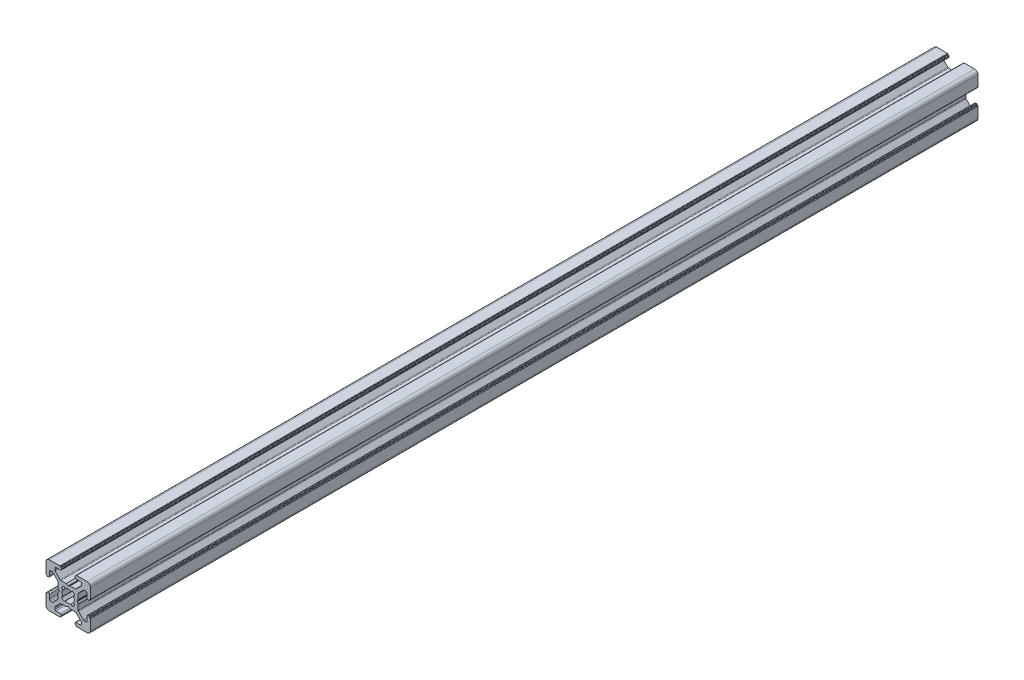
from build123d import *

# Parameters (mm, degrees)
DODANIE_WYCI_GNI_CIE1_DEPTH = 400


with BuildPart() as part:
    # Szkic1 → Dodanie-wyciągnięcie1 (new body)
    with BuildSketch(Plane.XY):
        with BuildLine():
            Line((6.249999773, 6.250000395), (1.5, 6.250000395))
            ThreePointArc((1.5, 6.250000395), (0.439339828, 5.810660567), (0, 4.750000395))
            Line((0, 4.750000395), (0, 0))
            ThreePointArc((0, 0), (0.058578644, -0.141421356), (0.2, -0.2))
            Line((0.2, -0.2), (0.300000268, -0.2))
            ThreePointArc((0.300000268, -0.2), (0.441421624, -0.258578644), (0.500000268, -0.4))
            Line((0.500000268, -0.4), (0.500000268, -0.549999605))
            ThreePointArc((0.500000268, -0.549999605), (0.558578912, -0.691420961), (0.700000268, -0.749999605))
            Line((0.700000268, -0.749999605), (1.000000268, -0.749999605))
            ThreePointArc((1.000000268, -0.749999605), (1.353553659, -0.603552995), (1.500000268, -0.249999605))
            Line((1.500000268, -0.249999605), (1.500000268, 1.75))
            ThreePointArc((1.500000268, 1.75), (1.646446877, 2.103553391), (2.000000268, 2.25))
            Line((2.000000268, 2.25), (2.732233315, 2.25))
            ThreePointArc((2.732233315, 2.25), (2.923575031, 2.211939766), (3.085786706, 2.103553391))
            Line((3.085786706, 2.103553391), (5.353553602, -0.164213506))
            ThreePointArc((5.353553602, -0.164213506), (5.461939977, -0.32642518), (5.500000211, -0.517766896))
            Line((5.500000211, -0.517766896), (5.500000211, -2.796410303))
            ThreePointArc((5.500000211, -2.796410303), (5.506815047, -2.848174114), (5.526795133, -2.896410307))
            Line((5.526795133, -2.896410307), (5.961880159, -3.649999636))
            ThreePointArc((5.961880159, -3.649999636), (5.988675071, -3.749999605), (5.961880159, -3.849999574))
            Line((5.961880159, -3.849999574), (5.526795133, -4.603588902))
            ThreePointArc((5.526795133, -4.603588902), (5.506815046, -4.651825095), (5.500000211, -4.703588906))
            Line((5.500000211, -4.703588906), (5.500000211, -6.982232313))
            ThreePointArc((5.500000211, -6.982232313), (5.461939977, -7.173574029), (5.353553602, -7.335785704))
            Line((5.353553602, -7.335785704), (3.085786706, -9.6035526))
            ThreePointArc((3.085786706, -9.6035526), (2.923575031, -9.711938976), (2.732233315, -9.749999209))
            Line((2.732233315, -9.749999209), (2.000000268, -9.749999209))
            ThreePointArc((2.000000268, -9.749999209), (1.646446877, -9.6035526), (1.500000268, -9.249999209))
            Line((1.500000268, -9.249999209), (1.500000268, -7.249999605))
            ThreePointArc((1.500000268, -7.249999605), (1.353553659, -6.896446214), (1.000000268, -6.749999605))
            Line((1.000000268, -6.749999605), (0.700000268, -6.749999605))
            ThreePointArc((0.700000268, -6.749999605), (0.558578912, -6.808578248), (0.500000268, -6.949999605))
            Line((0.500000268, -6.949999605), (0.500000268, -7.099999209))
            ThreePointArc((0.500000268, -7.099999209), (0.441421624, -7.241420566), (0.300000268, -7.299999209))
            Line((0.300000268, -7.299999209), (0.2, -7.299999209))
            ThreePointArc((0.2, -7.299999209), (0.058578644, -7.358577853), (0, -7.499999209))
            Line((0, -7.499999209), (0, -12.249999605))
            ThreePointArc((0, -12.249999605), (0.439339828, -13.310659776), (1.5, -13.749999605))
            Line((1.5, -13.749999605), (6.249999772, -13.749999605))
            ThreePointArc((6.249999772, -13.749999605), (6.391421129, -13.691420961), (6.449999772, -13.549999605))
            Line((6.449999772, -13.549999605), (6.449999772, -13.449999605))
            ThreePointArc((6.449999772, -13.449999605), (6.508578416, -13.308578248), (6.649999772, -13.249999605))
            Line((6.649999772, -13.249999605), (6.8, -13.249999605))
            ThreePointArc((6.8, -13.249999605), (6.941421356, -13.191420961), (7, -13.049999605))
            Line((7, -13.049999605), (7, -12.749999278))
            ThreePointArc((7, -12.749999278), (6.853553391, -12.396445888), (6.5, -12.249999278))
            Line((6.5, -12.249999278), (4.499999314, -12.249999278))
            ThreePointArc((4.499999314, -12.249999278), (4.146445923, -12.103552669), (3.999999314, -11.749999278))
            Line((3.999999314, -11.749999278), (3.999999314, -11.017766231))
            ThreePointArc((3.999999314, -11.017766231), (4.038059552, -10.826424504), (4.146445941, -10.664212823))
            Line((4.146445941, -10.664212823), (6.414212788, -8.396446197))
            ThreePointArc((6.414212788, -8.396446197), (6.576424456, -8.288059834), (6.767766161, -8.249999605))
            Line((6.767766161, -8.249999605), (9.046409688, -8.249999605))
            ThreePointArc((9.046409688, -8.249999605), (9.098173495, -8.243184771), (9.146409684, -8.223204688))
            Line((9.146409684, -8.223204688), (9.899999955, -7.788119166))
            ThreePointArc((9.899999955, -7.788119166), (10, -7.761324236), (10.100000045, -7.788119166))
            Line((10.100000045, -7.788119166), (10.853590316, -8.223204688))
            ThreePointArc((10.853590316, -8.223204688), (10.901826505, -8.243184771), (10.953590312, -8.249999605))
            Line((10.953590312, -8.249999605), (13.232233839, -8.249999605))
            ThreePointArc((13.232233839, -8.249999605), (13.423575544, -8.288059834), (13.585787212, -8.396446197))
            Line((13.585787212, -8.396446197), (15.853554059, -10.664212823))
            ThreePointArc((15.853554059, -10.664212823), (15.961940448, -10.826424504), (16.000000686, -11.017766231))
            Line((16.000000686, -11.017766231), (16.000000686, -11.749999278))
            ThreePointArc((16.000000686, -11.749999278), (15.853554077, -12.103552669), (15.500000686, -12.249999278))
            Line((15.500000686, -12.249999278), (13.5, -12.249999278))
            ThreePointArc((13.5, -12.249999278), (13.146446609, -12.396445888), (13, -12.749999278))
            Line((13, -12.749999278), (13, -13.049999605))
            ThreePointArc((13, -13.049999605), (13.058578644, -13.191420961), (13.2, -13.249999605))
            Line((13.2, -13.249999605), (13.350000227, -13.249999605))
            ThreePointArc((13.350000227, -13.249999605), (13.491421584, -13.308578248), (13.550000227, -13.449999605))
            Line((13.550000227, -13.449999605), (13.550000227, -13.549999605))
            ThreePointArc((13.550000227, -13.549999605), (13.608578871, -13.691420961), (13.750000227, -13.749999605))
            Line((13.750000227, -13.749999605), (18.5, -13.749999605))
            ThreePointArc((18.5, -13.749999605), (19.560660172, -13.310659776), (20, -12.249999605))
            Line((20, -12.249999605), (20, -7.499999209))
            ThreePointArc((20, -7.499999209), (19.941421356, -7.358577853), (19.8, -7.299999209))
            Line((19.8, -7.299999209), (19.699999732, -7.299999209))
            ThreePointArc((19.699999732, -7.299999209), (19.558578376, -7.241420566), (19.499999732, -7.099999209))
            Line((19.499999732, -7.099999209), (19.499999732, -6.949999605))
            ThreePointArc((19.499999732, -6.949999605), (19.441421088, -6.808578248), (19.299999732, -6.749999605))
            Line((19.299999732, -6.749999605), (18.999999732, -6.749999605))
            ThreePointArc((18.999999732, -6.749999605), (18.646446341, -6.896446214), (18.499999732, -7.249999605))
            Line((18.499999732, -7.249999605), (18.499999732, -9.249999209))
            ThreePointArc((18.499999732, -9.249999209), (18.353553123, -9.6035526), (17.999999732, -9.749999209))
            Line((17.999999732, -9.749999209), (17.267766685, -9.749999209))
            ThreePointArc((17.267766685, -9.749999209), (17.076424969, -9.711938976), (16.914213294, -9.6035526))
            Line((16.914213294, -9.6035526), (14.646446398, -7.335785704))
            ThreePointArc((14.646446398, -7.335785704), (14.538060023, -7.173574029), (14.499999789, -6.982232313))
            Line((14.499999789, -6.982232313), (14.499999789, -4.703588906))
            ThreePointArc((14.499999789, -4.703588906), (14.493184953, -4.651825095), (14.473204867, -4.603588902))
            Line((14.473204867, -4.603588902), (14.038119841, -3.849999574))
            ThreePointArc((14.038119841, -3.849999574), (14.011324929, -3.749999605), (14.038119841, -3.649999636))
            Line((14.038119841, -3.649999636), (14.473204867, -2.896410307))
            ThreePointArc((14.473204867, -2.896410307), (14.493184953, -2.848174114), (14.499999789, -2.796410303))
            Line((14.499999789, -2.796410303), (14.499999789, -0.517766896))
            ThreePointArc((14.499999789, -0.517766896), (14.538060023, -0.32642518), (14.646446398, -0.164213506))
            Line((14.646446398, -0.164213506), (16.914213294, 2.103553391))
            ThreePointArc((16.914213294, 2.103553391), (17.076424969, 2.211939766), (17.267766685, 2.25))
            Line((17.267766685, 2.25), (17.999999732, 2.25))
            ThreePointArc((17.999999732, 2.25), (18.353553123, 2.103553391), (18.499999732, 1.75))
            Line((18.499999732, 1.75), (18.499999732, -0.249999605))
            ThreePointArc((18.499999732, -0.249999605), (18.646446341, -0.603552995), (18.999999732, -0.749999605))
            Line((18.999999732, -0.749999605), (19.299999732, -0.749999605))
            ThreePointArc((19.299999732, -0.749999605), (19.441421088, -0.691420961), (19.499999732, -0.549999605))
            Line((19.499999732, -0.549999605), (19.499999732, -0.4))
            ThreePointArc((19.499999732, -0.4), (19.558578376, -0.258578644), (19.699999732, -0.2))
            Line((19.699999732, -0.2), (19.8, -0.2))
            ThreePointArc((19.8, -0.2), (19.941421356, -0.141421356), (20, 0))
            Line((20, 0), (20, 4.750000395))
            ThreePointArc((20, 4.750000395), (19.560660172, 5.810660567), (18.5, 6.250000395))
            Line((18.5, 6.250000395), (13.750000228, 6.250000395))
            ThreePointArc((13.750000228, 6.250000395), (13.608578871, 6.191421752), (13.550000228, 6.050000395))
            Line((13.550000228, 6.050000395), (13.550000228, 5.950000395))
            ThreePointArc((13.550000228, 5.950000395), (13.491421584, 5.808579039), (13.350000228, 5.750000395))
            Line((13.350000228, 5.750000395), (13.2, 5.750000395))
            ThreePointArc((13.2, 5.750000395), (13.058578644, 5.691421752), (13, 5.550000395))
            Line((13, 5.550000395), (13, 5.250000069))
            ThreePointArc((13, 5.250000069), (13.146446609, 4.896446678), (13.5, 4.750000069))
            Line((13.5, 4.750000069), (15.500000686, 4.750000069))
            ThreePointArc((15.500000686, 4.750000069), (15.853554077, 4.603553459), (16.000000686, 4.250000069))
            Line((16.000000686, 4.250000069), (16.000000686, 3.517767022))
            ThreePointArc((16.000000686, 3.517767022), (15.961940448, 3.326425294), (15.853554059, 3.164213614))
            Line((15.853554059, 3.164213614), (13.585787212, 0.896446988))
            ThreePointArc((13.585787212, 0.896446988), (13.423575544, 0.788060624), (13.232233839, 0.750000395))
            Line((13.232233839, 0.750000395), (10.953590312, 0.750000395))
            ThreePointArc((10.953590312, 0.750000395), (10.901826505, 0.743185561), (10.853590316, 0.723205479))
            Line((10.853590316, 0.723205479), (10.100000045, 0.288119957))
            ThreePointArc((10.100000045, 0.288119957), (10, 0.261325027), (9.899999955, 0.288119957))
            Line((9.899999955, 0.288119957), (9.146409684, 0.723205479))
            ThreePointArc((9.146409684, 0.723205479), (9.098173495, 0.743185561), (9.046409688, 0.750000395))
            Line((9.046409688, 0.750000395), (6.767766161, 0.750000395))
            ThreePointArc((6.767766161, 0.750000395), (6.576424456, 0.788060624), (6.414212788, 0.896446988))
            Line((6.414212788, 0.896446988), (4.146445941, 3.164213614))
            ThreePointArc((4.146445941, 3.164213614), (4.038059552, 3.326425294), (3.999999314, 3.517767022))
            Line((3.999999314, 3.517767022), (3.999999314, 4.250000069))
            ThreePointArc((3.999999314, 4.250000069), (4.146445923, 4.603553459), (4.499999314, 4.750000069))
            Line((4.499999314, 4.750000069), (6.5, 4.750000069))
            ThreePointArc((6.5, 4.750000069), (6.853553391, 4.896446678), (7, 5.250000069))
            Line((7, 5.250000069), (7, 5.550000395))
            ThreePointArc((7, 5.550000395), (6.941421356, 5.691421752), (6.8, 5.750000395))
            Line((6.8, 5.750000395), (6.649999772, 5.750000395))
            ThreePointArc((6.649999772, 5.750000395), (6.508578416, 5.808579039), (6.449999772, 5.950000395))
            Line((6.449999772, 5.950000395), (6.449999772, 6.050000395))
            ThreePointArc((6.449999772, 6.050000395), (6.391421129, 6.191421752), (6.249999773, 6.250000395))
        make_face()
        with BuildLine():
            Line((7.007825047, -1.840068643), (7.554704576, -2.491814288))
            ThreePointArc((7.554704576, -2.491814288), (7.25, -3.749999605), (7.554704576, -5.008184922))
            Line((7.554704576, -5.008184922), (7.007825046, -5.659930566))
            ThreePointArc((7.007825046, -5.659930566), (7.488262739, -6.25841009), (8.08610498, -6.739640567))
            Line((8.08610498, -6.739640567), (8.741814564, -6.195294967))
            ThreePointArc((8.741814564, -6.195294967), (10, -6.499999605), (11.258185436, -6.195294967))
            Line((11.258185436, -6.195294967), (11.913895019, -6.739640567))
            ThreePointArc((11.913895019, -6.739640567), (12.511737261, -6.25841009), (12.992174953, -5.659930566))
            Line((12.992174953, -5.659930566), (12.445295423, -5.008184922))
            ThreePointArc((12.445295423, -5.008184922), (12.75, -3.749999605), (12.445295423, -2.491814288))
            Line((12.445295423, -2.491814288), (12.992174953, -1.840068643))
            ThreePointArc((12.992174953, -1.840068643), (12.511737261, -1.241589119), (11.913895019, -0.760358642))
            Line((11.913895019, -0.760358642), (11.258185436, -1.304704243))
            ThreePointArc((11.258185436, -1.304704243), (10, -0.999999605), (8.741814564, -1.304704243))
            Line((8.741814564, -1.304704243), (8.08610498, -0.760358642))
            ThreePointArc((8.08610498, -0.760358642), (7.488262739, -1.241589119), (7.007825047, -1.840068643))
        make_face(mode=Mode.SUBTRACT)
    extrude(amount=DODANIE_WYCI_GNI_CIE1_DEPTH)


solid = part.part
